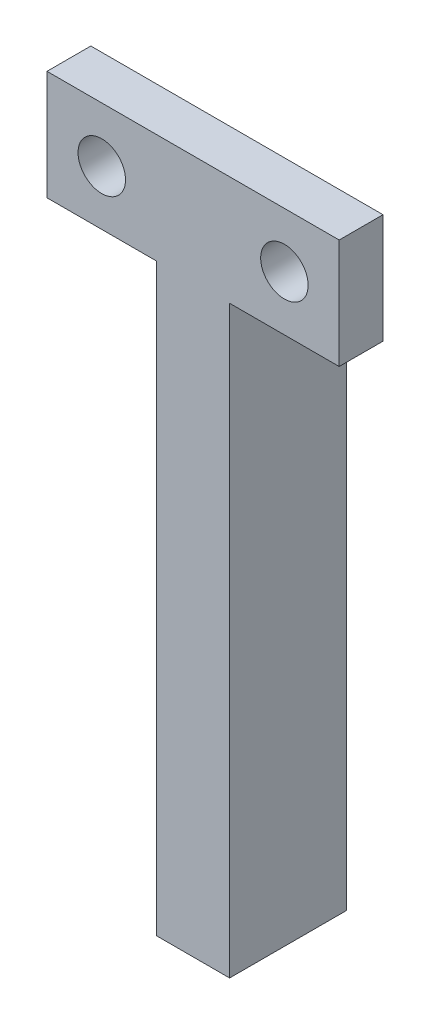
from build123d import *

# Parameters (mm, degrees)
SKETCH1_R           = 1.625
BOSS_EXTRUDE1_DEPTH = 3
SKETCH3_W           = 5
SKETCH3_H           = 40
BOSS_EXTRUDE3_DEPTH = 5


with BuildPart() as part:
    # Sketch1 → Boss-Extrude1 (new body)
    with BuildSketch(Plane.XY):
        Polygon((0, 0), (0, 40), (-7.5, 40), (-7.5, 47.5), (12.5, 47.5), (12.5, 40), (5, 40), (5, 0), align=None)
        with Locations((-3.75, 43.75)):
            Circle(SKETCH1_R, mode=Mode.SUBTRACT)
        with Locations((8.75, 43.75)):
            Circle(SKETCH1_R, mode=Mode.SUBTRACT)
    extrude(amount=BOSS_EXTRUDE1_DEPTH)

    # Sketch3 → Boss-Extrude3 (add)
    with BuildSketch(Plane(origin=(0, 0, 0), x_dir=(-1, 0, 0), z_dir=(0, 0, -1))):
        with Locations((-2.5, 20)):
            Rectangle(SKETCH3_W, SKETCH3_H)
    extrude(amount=BOSS_EXTRUDE3_DEPTH)


solid = part.part
